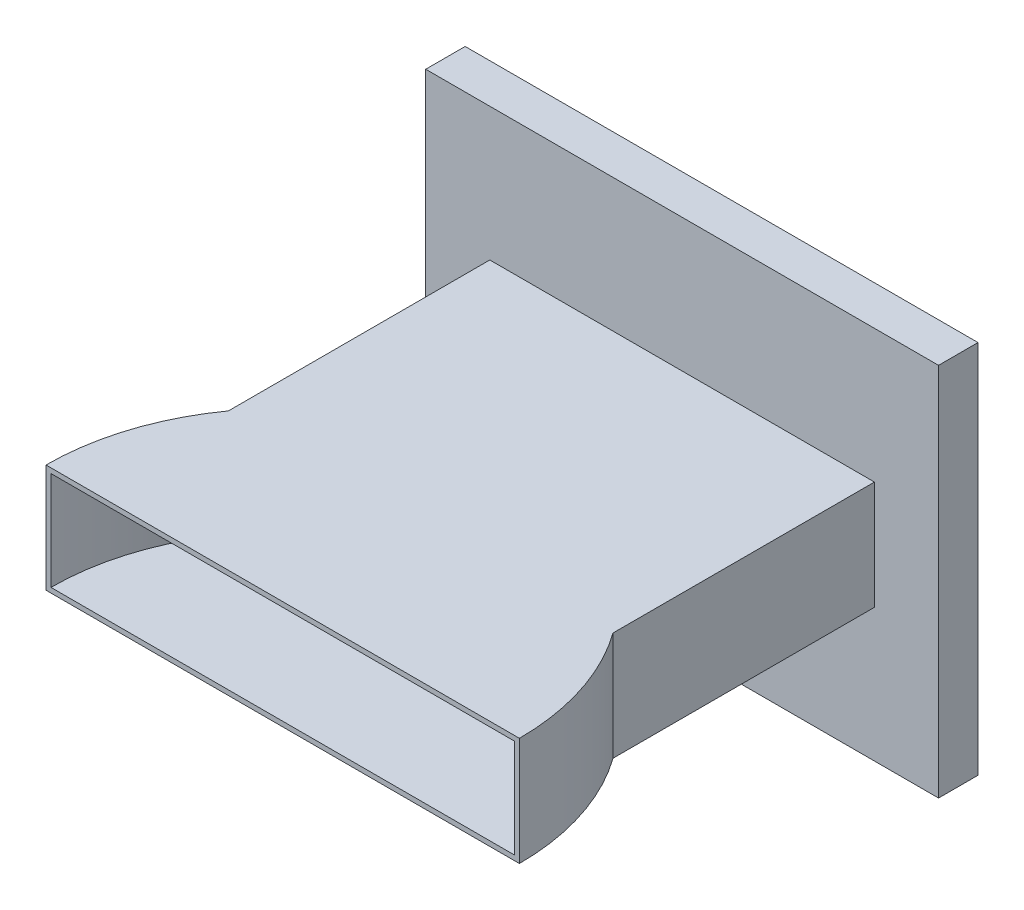
from build123d import *

# Parameters (mm, degrees)
SKETCH1_W                = 234
SKETCH1_H                = 66
SKETCH1_W_2              = 228
SKETCH1_H_2              = 60
BOSS_EXTRUDE1_DEPTH      = 243
BOSS_EXTRUDE2_DEPTH      = 66
SKETCH3_W                = 141
SKETCH3_H                = 60
SKETCH4_W                = 312
SKETCH4_H                = 24
BOSS_EXTRUDE3_DEPTH      = 147
BOSS_EXTRUDE3_DEPTH_BACK = 81


with BuildPart() as part:
    # Sketch1 → Boss-Extrude1 (new body)
    with BuildSketch(Plane.XY):
        with Locations((117, 33)):
            Rectangle(SKETCH1_W, SKETCH1_H)
        with Locations((117, 33)):
            Rectangle(SKETCH1_W_2, SKETCH1_H_2, mode=Mode.SUBTRACT)
    extrude(amount=BOSS_EXTRUDE1_DEPTH)

    # Sketch2 → Boss-Extrude2 (add)
    with BuildSketch(Plane.XZ):
        with BuildLine():
            Line((-27, 243), (261, 243))
            ThreePointArc((261, 243), (117, 99), (-27, 243))
        make_face()
    extrude(amount=-BOSS_EXTRUDE2_DEPTH)

    # Sketch3 → Cut-Revolve1 (revolve, cut)
    with BuildSketch(Plane.XY.offset(243)):
        with Locations((187.5, 33)):
            Rectangle(SKETCH3_W, SKETCH3_H)
    revolve(axis=Axis((117, 63, 243), (0, -1, 0)), mode=Mode.SUBTRACT)

    # Sketch4 → Boss-Extrude3 (add, two sides)
    with BuildSketch(Plane(origin=(0, 0, 0), x_dir=(1, 0, 0), z_dir=(0, 1, 0))) as boss_extrude3_sk:
        with Locations((117, 12)):
            Rectangle(SKETCH4_W, SKETCH4_H)
    extrude(amount=BOSS_EXTRUDE3_DEPTH)
    extrude(boss_extrude3_sk.sketch, amount=-BOSS_EXTRUDE3_DEPTH_BACK)


solid = part.part
